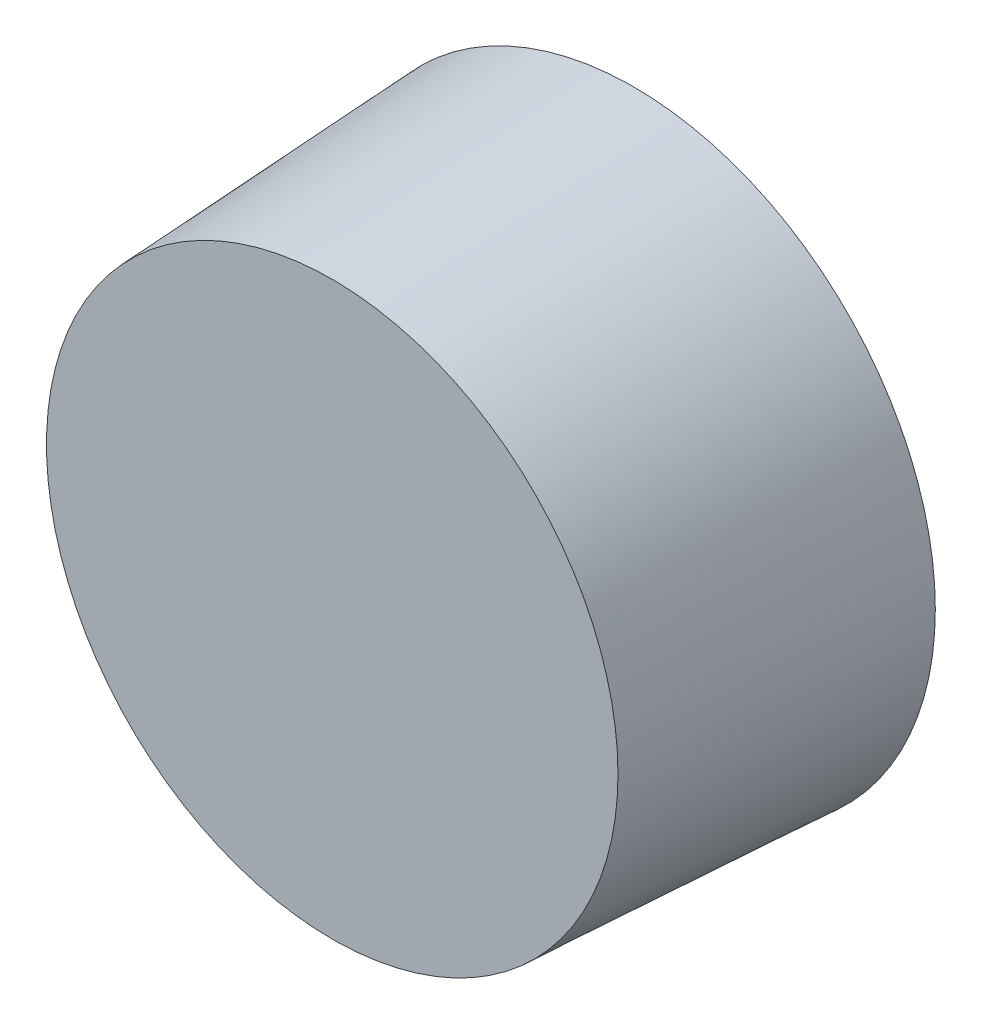
from build123d import *

# Parameters (mm, degrees)
SZKIC1_R                    = 50
DODANIE_WYCI_GNI_CIE1_DEPTH = 50
DODANIE_WYCI_GNI_CIE1_TAPER = 3
SZKIC2_R                    = 40
WYTNIJ_WYCI_GNI_CIE1_DEPTH  = 20
WYTNIJ_WYCI_GNI_CIE1_DRAFT  = -1


with BuildPart() as part:
    # Szkic1 → Dodanie-wyciągnięcie1 (new body)
    with BuildSketch(Plane.XY):
        Circle(SZKIC1_R)
    extrude(amount=DODANIE_WYCI_GNI_CIE1_DEPTH, taper=DODANIE_WYCI_GNI_CIE1_TAPER)


with BuildPart() as wytnij_wyci_gni_cie1_tool:
    # Szkic2 → Wytnij-wyciągnięcie1 (with draft: the straight prism first)
    with BuildSketch(Plane(origin=(0, 0, 0), x_dir=(-1, 0, 0), z_dir=(0, 0, -1))):
        Circle(SZKIC2_R)
    extrude(amount=-WYTNIJ_WYCI_GNI_CIE1_DEPTH)
    # Wytnij-wyciągnięcie1: the draft: its side faces are tilted about the plane it starts from
    wytnij_wyci_gni_cie1_sides = [wytnij_wyci_gni_cie1_tool.faces().sort_by_distance(p)[0] for p in [
        (40, 0, 10),
    ]]
    draft(wytnij_wyci_gni_cie1_sides, Plane(origin=(0, 0, 0), x_dir=(-1, 0, 0), z_dir=(0, 0, -1)), WYTNIJ_WYCI_GNI_CIE1_DRAFT)


with BuildPart() as part_1:
    add(part.part)

    # Wytnij-wyciągnięcie1: cut by wytnij_wyci_gni_cie1_tool
    add(wytnij_wyci_gni_cie1_tool.part, mode=Mode.SUBTRACT)


solid = part_1.part
